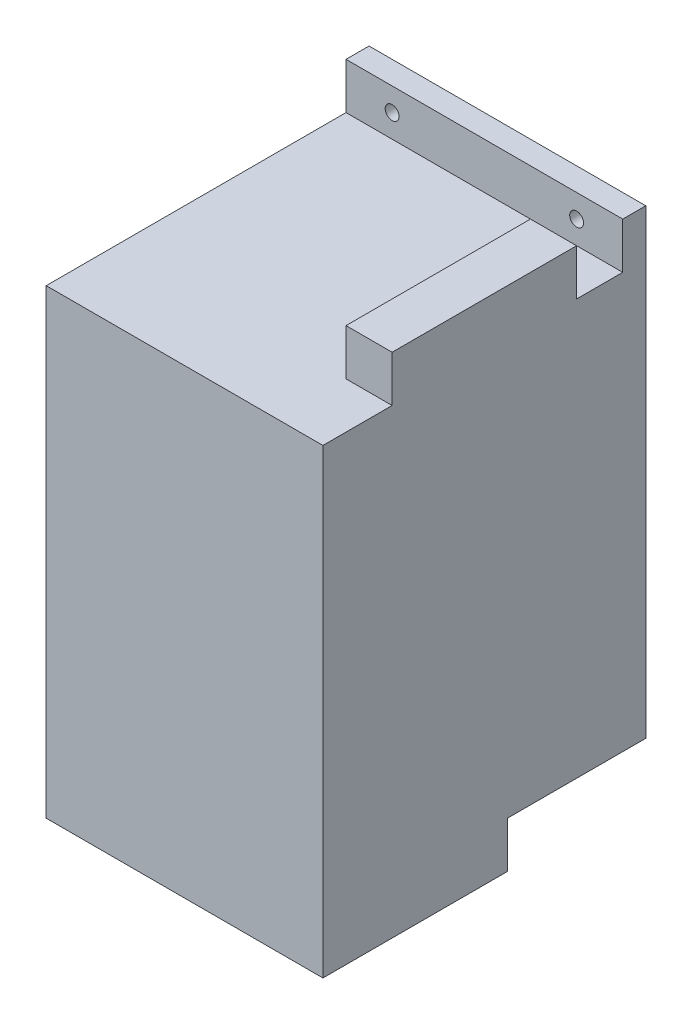
from build123d import *

# Parameters (mm, degrees)
SKETCH1_W           = 60
SKETCH1_H           = 70
BOSS_EXTRUDE1_DEPTH = 100
SKETCH2_W           = 10
SKETCH2_H           = 40
BOSS_EXTRUDE2_DEPTH = 10
SKETCH5_W           = 60
SKETCH5_H           = 5
BOSS_EXTRUDE4_DEPTH = 10
SKETCH6_R           = 1.5
CUT_EXTRUDE4_DEPTH  = 10
SKETCH7_W           = 60
SKETCH7_H           = 30
CUT_EXTRUDE5_DEPTH  = 10


with BuildPart() as part:
    # Sketch1 → Boss-Extrude1 (new body)
    with BuildSketch(Plane(origin=(0, 0, 0), x_dir=(1, 0, 0), z_dir=(0, 1, 0))):
        with Locations((30, 35)):
            Rectangle(SKETCH1_W, SKETCH1_H)
    extrude(amount=BOSS_EXTRUDE1_DEPTH)

    # Sketch2 → Boss-Extrude2 (add)
    with BuildSketch(Plane(origin=(0, 100, 0), x_dir=(1, 0, 0), z_dir=(0, 1, 0))):
        with Locations((55, 35)):
            Rectangle(SKETCH2_W, SKETCH2_H)
    extrude(amount=BOSS_EXTRUDE2_DEPTH)

    # Sketch5 → Boss-Extrude4 (add)
    with BuildSketch(Plane(origin=(0, 100, 0), x_dir=(1, 0, 0), z_dir=(0, 1, 0))):
        with Locations((30, 67.5)):
            Rectangle(SKETCH5_W, SKETCH5_H)
    extrude(amount=BOSS_EXTRUDE4_DEPTH)

    # Sketch6 → Cut-Extrude4 (cut)
    with BuildSketch(Plane(origin=(0, 0, -70), x_dir=(-1, 0, 0), z_dir=(0, 0, -1))):
        with Locations((-50, 105)):
            Circle(SKETCH6_R)
        with Locations((-10, 105)):
            Circle(SKETCH6_R)
    extrude(amount=-CUT_EXTRUDE4_DEPTH, mode=Mode.SUBTRACT)

    # Sketch7 → Cut-Extrude5 (cut)
    with BuildSketch(Plane.XZ):
        with Locations((30, -55)):
            Rectangle(SKETCH7_W, SKETCH7_H)
    extrude(amount=-CUT_EXTRUDE5_DEPTH, mode=Mode.SUBTRACT)


solid = part.part
